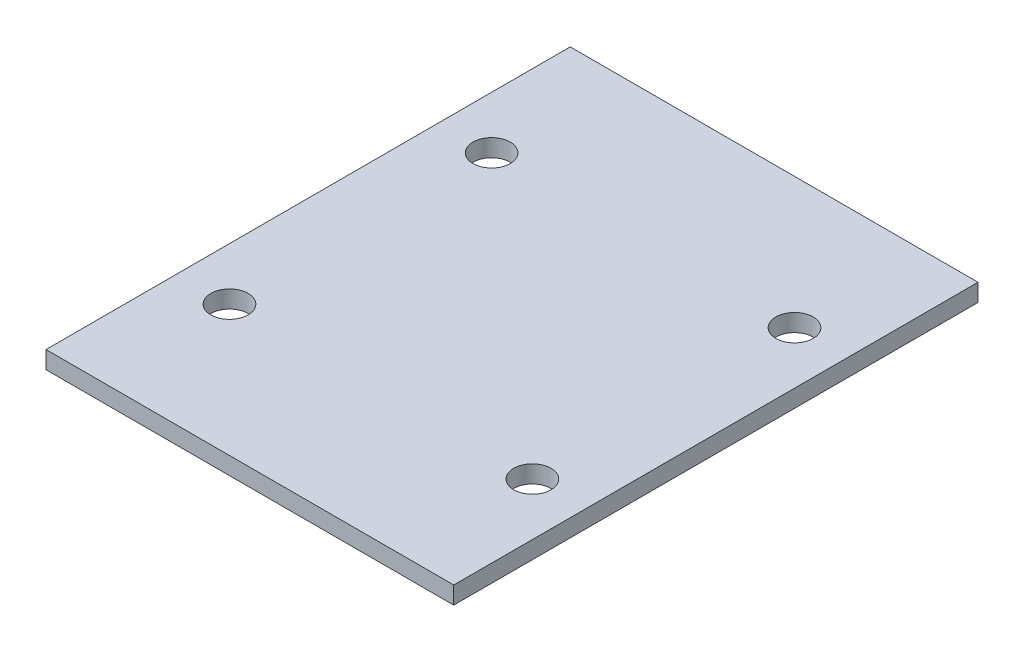
from build123d import *

# Parameters (mm, degrees)
CROQUIS1_W                   = 70
CROQUIS1_H                   = 90
SALIENTE_EXTRUIR1_DEPTH      = 3
TALADRO_DE_MARGEN_PARA_M61_D = 6.4


with BuildPart() as part:
    # Croquis1 → Saliente-Extruir1 (new body)
    with BuildSketch(Plane(origin=(0, 0, 0), x_dir=(1, 0, 0), z_dir=(0, 1, 0))):
        Rectangle(CROQUIS1_W, CROQUIS1_H)
    extrude(amount=SALIENTE_EXTRUIR1_DEPTH)

    # Taladro de margen para M61 (through all)
    with Locations(Plane(origin=(0, 3, 0), x_dir=(1, 0, 0), z_dir=(0, 1, 0))):
        with Locations((-26, 22.5), (26, 22.5), (26, -22.5), (-26, -22.5)):
            Hole(TALADRO_DE_MARGEN_PARA_M61_D / 2)


solid = part.part
